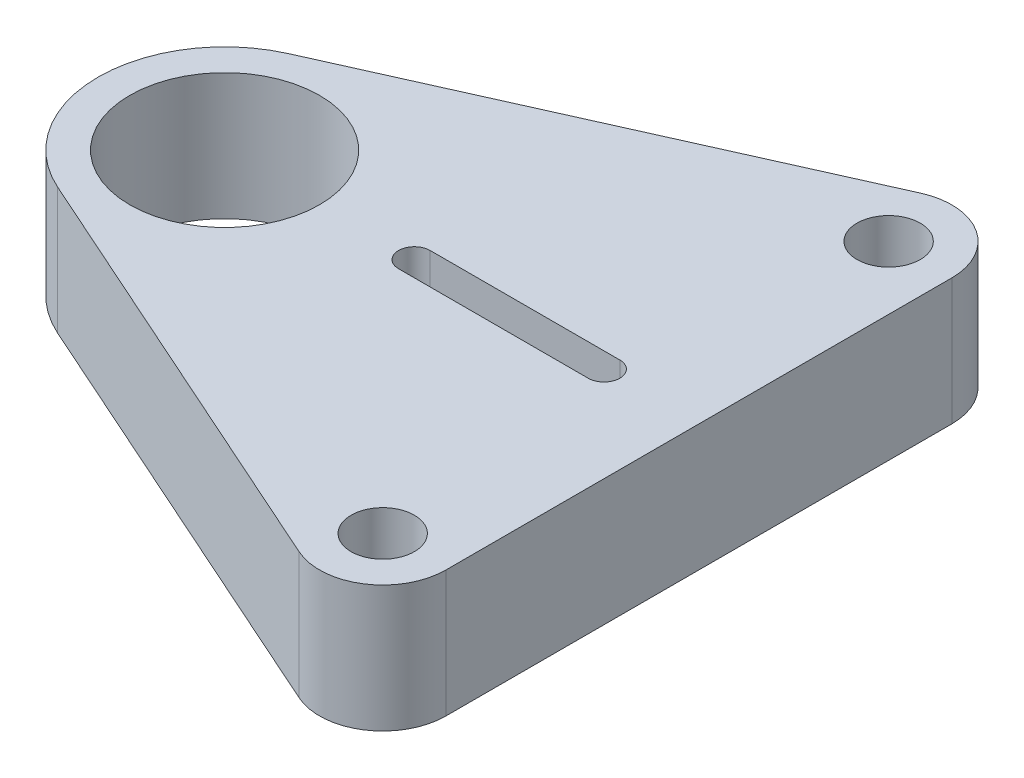
from build123d import *

# Parameters (mm, degrees)
BOSS_EXTRUDE1_DEPTH      = 20
BOSS_EXTRUDE1_DEPTH_BACK = 20
SKETCH1_R                = 30
SKETCH1_R_2              = 10


with BuildPart() as part:
    # Sketch1 → Boss-Extrude1 (new, two sides: drawn at the far end of the back side and taken through both)
    with BuildSketch(Plane(origin=(0, 0, 0), x_dir=(1, 0, 0), z_dir=(0, 1, 0)).offset(-BOSS_EXTRUDE1_DEPTH_BACK)):
        with BuildLine():
            Line((121.840174455, 98.259716511), (-16.319651091, 36.519433022))
            ThreePointArc((-16.319651091, 36.519433022), (-40, 0), (-16.319651091, -36.519433022))
            Line((-16.319651091, -36.519433022), (121.840174455, -98.259716511))
            ThreePointArc((121.840174455, -98.259716511), (140.88125657, -96.780889591), (150, -80))
            Line((150, -80), (150, 80))
            ThreePointArc((150, 80), (140.88125657, 96.780889591), (121.840174455, 98.259716511))
        make_face()
        Circle(SKETCH1_R, mode=Mode.SUBTRACT)
        with Locations((130, 80)):
            Circle(SKETCH1_R_2, mode=Mode.SUBTRACT)
        with Locations((130, -80)):
            Circle(SKETCH1_R_2, mode=Mode.SUBTRACT)
        with BuildLine():
            Line((60, -5), (120, -5))
            ThreePointArc((120, -5), (125, 0), (120, 5))
            Line((120, 5), (60, 5))
            ThreePointArc((60, 5), (55, 0), (60, -5))
        make_face(mode=Mode.SUBTRACT)
    extrude(amount=BOSS_EXTRUDE1_DEPTH + BOSS_EXTRUDE1_DEPTH_BACK)


solid = part.part
